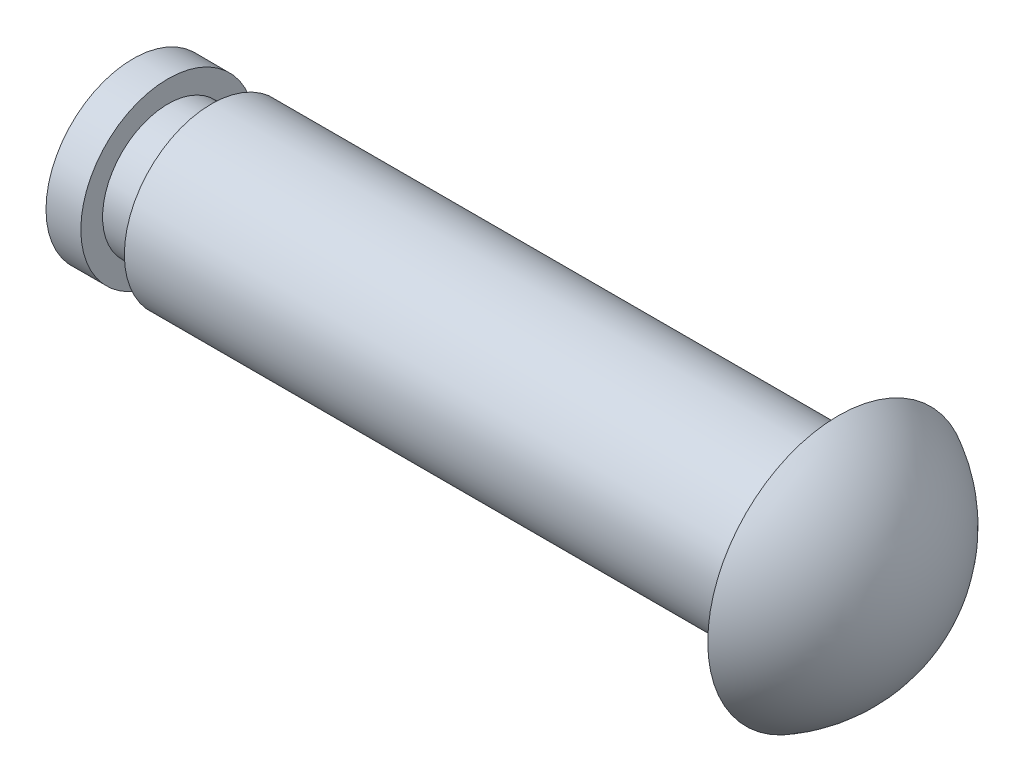
from build123d import *

# Parameters (mm, degrees)
SKETCH2_R               = 1
CUT_EXTRUDE1_DEPTH      = 7
CUT_EXTRUDE1_DEPTH_BACK = 7
SKETCH3_W               = 2
SKETCH3_H               = 1
SKETCH4_R               = 4
CUT_EXTRUDE2_DEPTH      = 2
SKETCH5_R               = 3
BOSS_EXTRUDE1_DEPTH     = 32.4


with BuildPart() as part:
    # Sketch1 → Revolve1 (revolve)
    with BuildSketch(Plane.XY):
        with BuildLine():
            Line((0, 4), (34.4, 4))
            Line((34.4, 4), (34.4, 6))
            ThreePointArc((34.4, 6), (37.030951895, 3.498571137), (38, 0))
            Line((38, 0), (0, 0))
            Line((0, 0), (0, 4))
        make_face()
    revolve(axis=Axis((0, 0, 0), (1, 0, 0)))

    # Sketch2 → Cut-Extrude1 (cut, two sides)
    with BuildSketch(Plane(origin=(0, 0, 0), x_dir=(1, 0, 0), z_dir=(0, 1, 0))) as cut_extrude1_sk:
        with Locations((4.6, 0)):
            Circle(SKETCH2_R)
    extrude(amount=CUT_EXTRUDE1_DEPTH, mode=Mode.SUBTRACT)
    extrude(cut_extrude1_sk.sketch, amount=-CUT_EXTRUDE1_DEPTH_BACK, mode=Mode.SUBTRACT)

    # Sketch3 → Cut-Revolve1 (revolve, cut)
    with BuildSketch(Plane(origin=(0, 0, 0), x_dir=(1, 0, 0), z_dir=(0, 1, 0))):
        with Locations((4.6, 3.5)):
            Rectangle(SKETCH3_W, SKETCH3_H)
    revolve(axis=Axis((34.4, 0, 0), (-1, 0, 0)), mode=Mode.SUBTRACT)

    # Sketch4 → Cut-Extrude2 (cut)
    with BuildSketch(Plane.ZY):
        Circle(SKETCH4_R)
    extrude(amount=-CUT_EXTRUDE2_DEPTH, mode=Mode.SUBTRACT)

    # Sketch5 → Boss-Extrude1 (add)
    with BuildSketch(Plane.ZY.offset(-2)):
        Circle(SKETCH5_R)
    extrude(amount=-BOSS_EXTRUDE1_DEPTH)


solid = part.part
